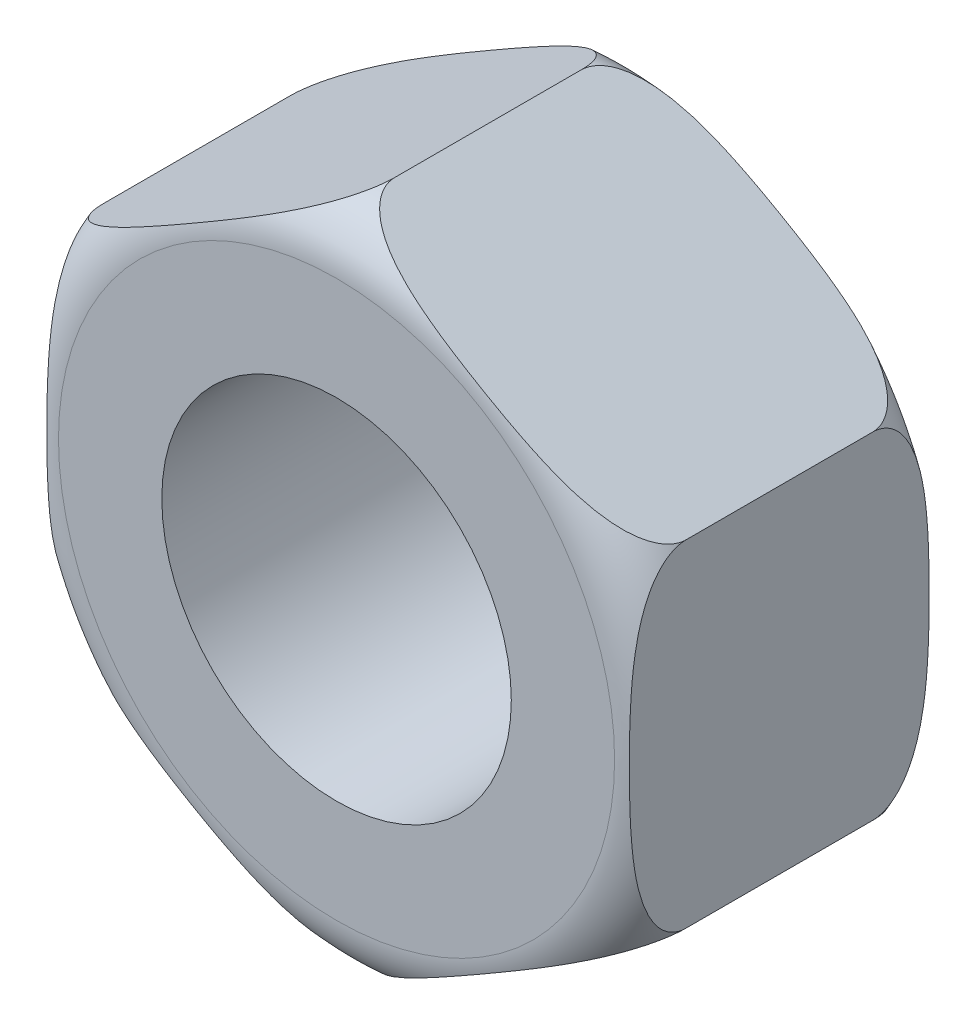
from build123d import *

# Parameters (mm, degrees)
HEAD_DEPTH         = 5.2
HOLE_SKETCH_R      = 3
THROUGH_HOLE_DEPTH = 6.2000001


with BuildPart() as part:
    # Head Sketch → Head (new body)
    with BuildSketch(Plane.XY):
        Polygon((0, 5.773502692), (5, 2.886751346), (5, -2.886751346), (0, -5.773502692), (-5, -2.886751346), (-5, 2.886751346), align=None)
    extrude(amount=HEAD_DEPTH)

    # Sketch5 → Head Trim (revolve, cut)
    with BuildSketch(Plane(origin=(0, 0, 0), x_dir=(0, 0, -1), z_dir=(1, 0, 0))):
        with BuildLine():
            Line((-5.2, -4.773502692), (-5.2, -5.773502692))
            Line((-5.2, -5.773502692), (-4.2, -5.773502692))
            ThreePointArc((-4.2, -5.773502692), (-4.907106781, -5.480609473), (-5.2, -4.773502692))
        make_face()
    head_trim = revolve(axis=Axis((0, 0, 15.085599173), (0, 0, -1)), mode=Mode.SUBTRACT)

    # Hole Sketch → Through Hole (cut, through all)
    with BuildSketch(Plane.XY.offset(5.2)):
        Circle(HOLE_SKETCH_R)
    extrude(amount=-THROUGH_HOLE_DEPTH, mode=Mode.SUBTRACT)

    # Symétrie2: Head Trim across plane
    add(head_trim.mirror(Plane.XY.offset(2.6)), mode=Mode.SUBTRACT)


solid = part.part
